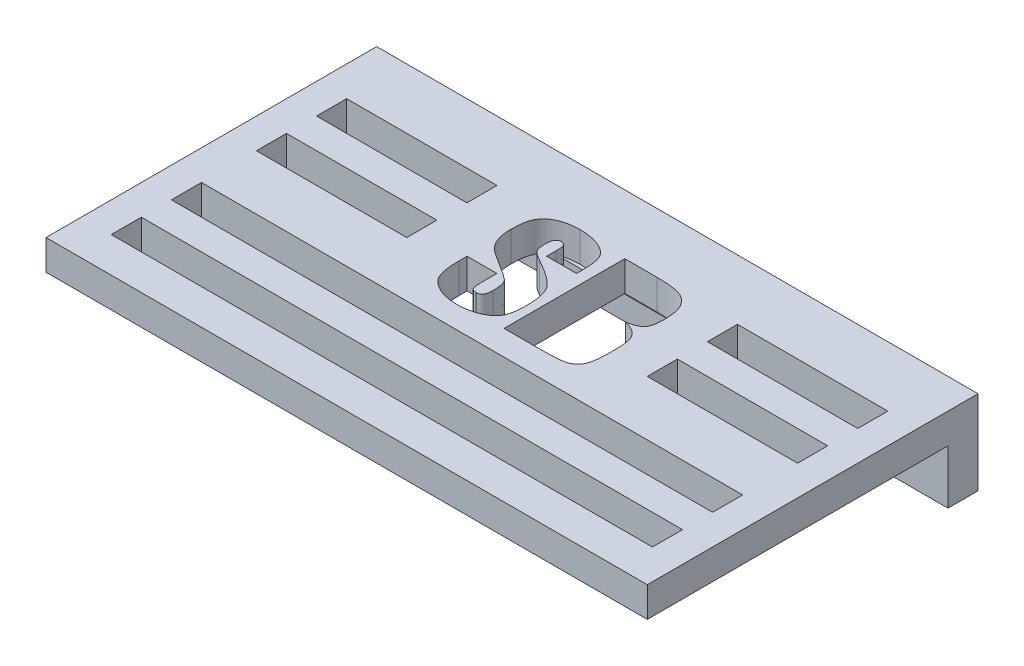
from build123d import *

# Parameters (mm, degrees)
SKETCH1_W           = 100
SKETCH1_H           = 50
BOSS_EXTRUDE1_DEPTH = 5
SKETCH2_W           = 100
SKETCH2_H           = 13.979624529
BOSS_EXTRUDE2_DEPTH = 5
SKETCH3_W           = 25
SKETCH3_H           = 5
SKETCH3_W_2         = 90
CUT_EXTRUDE1_DEPTH  = 5
CUT_EXTRUDE2_DEPTH  = 5
SKETCH5_W           = 5.529057523
SKETCH5_H           = 15.999161325
CUT_EXTRUDE3_DEPTH  = 5


with BuildPart() as part:
    # Sketch1 → Boss-Extrude1 (new body)
    with BuildSketch(Plane(origin=(0, 0, 0), x_dir=(1, 0, 0), z_dir=(0, 1, 0))):
        with Locations((1107.338709677, 577.567204301)):
            Rectangle(SKETCH1_W, SKETCH1_H)
    extrude(amount=BOSS_EXTRUDE1_DEPTH)

    # Sketch2 → Boss-Extrude2 (add)
    with BuildSketch(Plane(origin=(0, 0, -602.567204301), x_dir=(-1, 0, 0), z_dir=(0, 0, -1))):
        with Locations((-1107.338709677, -1.989812265)):
            Rectangle(SKETCH2_W, SKETCH2_H)
    extrude(amount=BOSS_EXTRUDE2_DEPTH)

    # Sketch3 → Cut-Extrude1 (cut)
    with BuildSketch(Plane(origin=(0, 5, 0), x_dir=(1, 0, 0), z_dir=(0, 1, 0))):
        with Locations((1074.838709677, 595.067204301)):
            Rectangle(SKETCH3_W, SKETCH3_H)
        with Locations((1139.838709677, 595.067204301)):
            Rectangle(SKETCH3_W, SKETCH3_H)
        with Locations((1139.838709677, 585.067204301)):
            Rectangle(SKETCH3_W, SKETCH3_H)
        with Locations((1074.838709677, 585.067204301)):
            Rectangle(SKETCH3_W, SKETCH3_H)
        with Locations((1107.338709677, 560.923142095)):
            Rectangle(SKETCH3_W_2, SKETCH3_H)
        with Locations((1107.338709677, 570.923142095)):
            Rectangle(SKETCH3_W_2, SKETCH3_H)
        with BuildLine():
            Line((1106.622574567, 591.504666387), (1101.661782977, 591.504666387))
            Line((1101.661782977, 591.504666387), (1101.661782977, 593.091824411))
            add(Edge.make_bspline(
                [(1101.661782977, 593.091824411), (1101.660519671, 593.260467079), (1101.658247272, 593.563816487), (1101.623631, 593.969134281), (1101.567949422, 594.276369068), (1101.480104346, 594.497949978), (1101.352985564, 594.64646604), (1101.19638039, 594.742361375), (1101.008066117, 594.804823716), (1100.871227987, 594.809409305), (1100.798073727, 594.811860781)],
                knots=[0, 0, 0, 0, 0.000505797, 0.000909813, 0.001218916, 0.001440411, 0.001615766, 0.001794963, 0.001985223, 0.002203776, 0.002203776, 0.002203776, 0.002203776], degree=3))
            add(Edge.make_bspline(
                [(1100.798073727, 594.811860781), (1100.718724347, 594.807066971), (1100.566086203, 594.797845497), (1100.350884239, 594.72171929), (1100.169040771, 594.59100808), (1100.017703118, 594.411626763), (1099.902676661, 594.180253753), (1099.831073964, 593.897343176), (1099.776182573, 593.567602693), (1099.773427651, 593.329571236), (1099.771957609, 593.202556366)],
                knots=[0, 0, 0, 0, 0.000237637, 0.000457123, 0.000674238, 0.00090204, 0.001154602, 0.001442079, 0.001774623, 0.002155089, 0.002155089, 0.002155089, 0.002155089], degree=3))
            add(Edge.make_bspline(
                [(1099.771957609, 593.202556366), (1099.773811748, 593.038706209), (1099.777278571, 592.732343195), (1099.827271783, 592.30569647), (1099.89577488, 591.939364377), (1099.982870155, 591.727609085), (1100.022950041, 591.630162603)],
                knots=[0, 0, 0, 0, 0.000491134, 0.00091831, 0.001288246, 0.00160361, 0.00160361, 0.00160361, 0.00160361], degree=3))
            add(Edge.make_bspline(
                [(1100.022950041, 591.630162603), (1100.047682192, 591.585158602), (1100.1007808, 591.488537414), (1100.211328399, 591.348238897), (1100.351801328, 591.199381722), (1100.529971675, 591.05226491), (1100.735457754, 590.893960242), (1100.974959613, 590.733105124), (1101.248679918, 590.568360619), (1101.442518799, 590.458411939), (1101.543668892, 590.401037901)],
                knots=[0, 0, 0, 0, 0.000153834, 0.000330273, 0.000533918, 0.000766923, 0.001022355, 0.001312074, 0.001631751, 0.00198061, 0.00198061, 0.00198061, 0.00198061], degree=3))
            add(Edge.make_bspline(
                [(1101.543668892, 590.401037901), (1101.836084256, 590.237603929), (1102.396319738, 589.924482524), (1103.187570699, 589.452326344), (1103.892671397, 589.000526415), (1104.510900685, 588.566920629), (1105.048370108, 588.161578328), (1105.495975834, 587.771080348), (1105.870343557, 587.411878993), (1106.064225792, 587.156483361), (1106.15380929, 587.03847753)],
                knots=[0, 0, 0, 0, 0.001004926, 0.001925327, 0.002763857, 0.00351649, 0.004190512, 0.004781843, 0.005298618, 0.005742483, 0.005742483, 0.005742483, 0.005742483], degree=3))
            add(Edge.make_bspline(
                [(1106.15380929, 587.03847753), (1106.23056521, 586.919563128), (1106.38980434, 586.672861293), (1106.578438953, 586.256034755), (1106.736540033, 585.789261002), (1106.868068819, 585.27338085), (1106.970934318, 584.704787569), (1107.042536959, 584.085902866), (1107.087412887, 583.415745425), (1107.092430943, 582.952544013), (1107.095030909, 582.71254915)],
                knots=[0, 0, 0, 0, 0.000424135, 0.000879918, 0.001367838, 0.001901398, 0.00247551, 0.003099987, 0.003769537, 0.004489446, 0.004489446, 0.004489446, 0.004489446], degree=3))
            add(Edge.make_bspline(
                [(1107.095030909, 582.71254915), (1107.094049095, 582.537801365), (1107.092146513, 582.199171078), (1107.065253586, 581.70919557), (1107.025294711, 581.254856746), (1106.972060591, 580.836717463), (1106.897355591, 580.455009818), (1106.810214387, 580.108204793), (1106.707627412, 579.795087805), (1106.585083717, 579.513886534), (1106.437609289, 579.256568825), (1106.261612904, 579.015479931), (1106.058626025, 578.782444266), (1105.824452352, 578.560867655), (1105.560842619, 578.348957816), (1105.265305647, 578.15189465), (1104.941077761, 577.962299109), (1104.467514652, 577.719664952), (1103.821187849, 577.468217492), (1102.989604562, 577.248680005), (1102.097662469, 577.119781031), (1101.48257242, 577.103233059), (1101.167180244, 577.094747959)],
                knots=[0, 0, 0, 0, 0.000524183, 0.001015774, 0.001471587, 0.001892336, 0.002279617, 0.002637707, 0.002964528, 0.00326697, 0.003556313, 0.003852382, 0.004161066, 0.004482189, 0.004818258, 0.005174517, 0.005546748, 0.005944579, 0.006769827, 0.007621256, 0.008520135, 0.009466085, 0.009466085, 0.009466085, 0.009466085], degree=3))
            add(Edge.make_bspline(
                [(1101.167180244, 577.094747959), (1100.991135927, 577.096054821), (1100.64592821, 577.098617464), (1100.138673202, 577.142950043), (1099.651500804, 577.202870526), (1099.183338193, 577.292909798), (1098.733947278, 577.405324903), (1098.304815825, 577.547947285), (1097.892879354, 577.707292832), (1097.507708948, 577.900882197), (1097.146351682, 578.110202289), (1096.814787726, 578.333454417), (1096.516410571, 578.572101049), (1096.249481104, 578.82254317), (1096.014967246, 579.089052864), (1095.816537918, 579.371615066), (1095.642672889, 579.662859038), (1095.509711959, 579.977281803), (1095.400104408, 580.312728007), (1095.301923899, 580.676903762), (1095.228770546, 581.075019818), (1095.160204381, 581.505419496), (1095.110309975, 581.968663008), (1095.073589936, 582.464757693), (1095.051329246, 582.992866384), (1095.048731946, 583.356003033), (1095.04739419, 583.543038813)],
                knots=[0, 0, 0, 0, 0.000527938, 0.001035242, 0.001526486, 0.001999922, 0.002464542, 0.002915094, 0.003355817, 0.003788302, 0.004206762, 0.004608071, 0.004986221, 0.005351767, 0.005704896, 0.006049017, 0.006386442, 0.006720376, 0.007070541, 0.00744478, 0.007850881, 0.008284168, 0.008752104, 0.009248083, 0.009776369, 0.01033746, 0.01033746, 0.01033746, 0.01033746], degree=3))
            Line((1095.04739419, 583.543038813), (1095.04739419, 584.890277601))
            Line((1095.04739419, 584.890277601), (1100.00818578, 584.890277601))
            Line((1100.00818578, 584.890277601), (1100.00818578, 582.288076655))
            add(Edge.make_bspline(
                [(1100.00818578, 582.288076655), (1100.008637117, 582.192082505), (1100.009493837, 582.009867766), (1100.022726451, 581.750377429), (1100.03352159, 581.517108637), (1100.062506571, 581.310904607), (1100.087368923, 581.129543819), (1100.130397308, 580.977596882), (1100.172366116, 580.850122199), (1100.240257665, 580.716831383), (1100.356740276, 580.585429685), (1100.53899432, 580.474387188), (1100.76478348, 580.413190095), (1100.928115092, 580.405872763), (1101.015846572, 580.401942353)],
                knots=[0, 0, 0, 0, 0.000287927, 0.000546538, 0.000779544, 0.000987852, 0.001171109, 0.001327794, 0.001460878, 0.001573137, 0.001774529, 0.001978374, 0.002205007, 0.002468007, 0.002468007, 0.002468007, 0.002468007], degree=3))
            add(Edge.make_bspline(
                [(1101.015846572, 580.401942353), (1101.105247193, 580.405835871), (1101.275951231, 580.413270265), (1101.511159944, 580.499115925), (1101.713111322, 580.631068973), (1101.869440061, 580.825130822), (1101.993095617, 581.067214064), (1102.072477668, 581.361268648), (1102.125191448, 581.702998563), (1102.131084141, 581.947024772), (1102.134239319, 582.07768594)],
                knots=[0, 0, 0, 0, 0.00026701, 0.000509836, 0.000741198, 0.000982222, 0.001248005, 0.001551705, 0.001891544, 0.002283232, 0.002283232, 0.002283232, 0.002283232], degree=3))
            add(Edge.make_bspline(
                [(1102.134239319, 582.07768594), (1102.132984609, 582.222905918), (1102.130579914, 582.501224933), (1102.108119819, 582.898934617), (1102.073925451, 583.259306316), (1102.017389329, 583.577920831), (1101.954278097, 583.859859434), (1101.8680436, 584.098343883), (1101.775867339, 584.304850138), (1101.690908008, 584.416614998), (1101.650709782, 584.469496171)],
                knots=[0, 0, 0, 0, 0.000435608, 0.000834858, 0.001194789, 0.00152065, 0.001805341, 0.002059837, 0.002281054, 0.002479722, 0.002479722, 0.002479722, 0.002479722], degree=3))
            add(Edge.make_bspline(
                [(1101.650709782, 584.469496171), (1101.602300283, 584.520771899), (1101.493388133, 584.636132518), (1101.292537344, 584.806486871), (1101.042598105, 584.997655855), (1100.749204711, 585.215844054), (1100.403333029, 585.451624393), (1100.009883249, 585.709354485), (1099.564056577, 585.986116788), (1099.250422975, 586.177454707), (1099.085419488, 586.278118105)],
                knots=[0, 0, 0, 0, 0.000211424, 0.000475664, 0.000788709, 0.001155613, 0.001572311, 0.002044263, 0.002566584, 0.003146446, 0.003146446, 0.003146446, 0.003146446], degree=3))
            add(Edge.make_bspline(
                [(1099.085419488, 586.278118105), (1098.920346854, 586.378673703), (1098.60279486, 586.572113585), (1098.150936623, 586.854661729), (1097.74237591, 587.117933583), (1097.38002398, 587.360048881), (1097.058994176, 587.578745066), (1096.783574223, 587.777240974), (1096.549210967, 587.953561185), (1096.295112723, 588.165867733), (1096.020499726, 588.448827748), (1095.727901374, 588.831350885), (1095.466546177, 589.270657833), (1095.231393364, 589.765318041), (1095.036332423, 590.325510129), (1094.910718024, 590.960146096), (1094.821637445, 591.662094758), (1094.814758011, 592.15520067), (1094.811166019, 592.41266842)],
                knots=[0, 0, 0, 0, 0.000579862, 0.001115486, 0.001598734, 0.002037908, 0.00242286, 0.002763979, 0.00305632, 0.003302545, 0.003756711, 0.004235839, 0.004744148, 0.00528735, 0.005876823, 0.006518219, 0.007224641, 0.007996507, 0.007996507, 0.007996507, 0.007996507], degree=3))
            add(Edge.make_bspline(
                [(1094.811166019, 592.41266842), (1094.813882699, 592.600928364), (1094.819123317, 592.964091774), (1094.842429626, 593.488953534), (1094.891279076, 593.974095394), (1094.955961137, 594.420403845), (1095.041123857, 594.828347634), (1095.141474187, 595.19872243), (1095.267926483, 595.527498964), (1095.409624184, 595.822389016), (1095.575063677, 596.089042794), (1095.764838188, 596.334574056), (1095.971719393, 596.571947084), (1096.209175435, 596.786331941), (1096.466102761, 596.991954434), (1096.745221032, 597.183610443), (1097.050028252, 597.35646293), (1097.490559719, 597.572188672), (1098.094362364, 597.79394742), (1098.880175591, 597.98581086), (1099.73536491, 598.100344835), (1100.328948599, 598.112680866), (1100.635666859, 598.119055174)],
                knots=[0, 0, 0, 0, 0.000564842, 0.001089609, 0.001575514, 0.002027047, 0.002441845, 0.002825147, 0.003176807, 0.003497059, 0.003805368, 0.004116164, 0.004427288, 0.00474858, 0.005074274, 0.005414172, 0.005763032, 0.006124549, 0.006884881, 0.007686998, 0.008547278, 0.009467094, 0.009467094, 0.009467094, 0.009467094], degree=3))
            add(Edge.make_bspline(
                [(1100.635666859, 598.119055174), (1100.806702459, 598.116489597), (1101.142876423, 598.111446904), (1101.637314565, 598.084830146), (1102.110550556, 598.025100546), (1102.566502223, 597.959833501), (1103.001659688, 597.860772251), (1103.419212433, 597.748845365), (1103.816143031, 597.611432324), (1104.191194903, 597.452630654), (1104.54175857, 597.280390384), (1104.866947872, 597.101952762), (1105.153664587, 596.901975241), (1105.419803213, 596.704201442), (1105.64323331, 596.481137957), (1105.847342334, 596.258096124), (1106.012153281, 596.01714449), (1106.150817884, 595.761472522), (1106.260877798, 595.476415971), (1106.361458804, 595.156508134), (1106.439540018, 594.790182143), (1106.511189919, 594.381852425), (1106.560112724, 593.926783548), (1106.596715078, 593.428217322), (1106.618724672, 592.88532004), (1106.621258465, 592.508656285), (1106.622574567, 592.31300966)],
                knots=[0, 0, 0, 0, 0.000513178, 0.001008661, 0.00148435, 0.001943736, 0.002389729, 0.00282223, 0.00324012, 0.003648696, 0.004043226, 0.004411778, 0.004759856, 0.005091353, 0.005404594, 0.005705297, 0.005997101, 0.006277841, 0.006575996, 0.006912227, 0.007282954, 0.007698621, 0.008155554, 0.008655213, 0.009198251, 0.009785177, 0.009785177, 0.009785177, 0.009785177], degree=3))
            Line((1106.622574567, 592.31300966), (1106.622574567, 591.504666387))
        make_face()
        with BuildLine():
            Line((1108.512399935, 597.646598832), (1113.838606977, 597.646598832))
            add(Edge.make_bspline(
                [(1113.838606977, 597.646598832), (1114.042851135, 597.644585937), (1114.437854849, 597.640693041), (1115.011437917, 597.627741715), (1115.547024533, 597.599219161), (1116.043865141, 597.55291118), (1116.503700196, 597.504399163), (1116.924602135, 597.437078935), (1117.307872242, 597.360815888), (1117.657583265, 597.272605536), (1117.979536692, 597.163827426), (1118.283450436, 597.036016088), (1118.569738952, 596.8793132), (1118.83907191, 596.697421237), (1119.09578723, 596.493845885), (1119.335131088, 596.265001294), (1119.558066535, 596.01145837), (1119.76684219, 595.733032269), (1119.958520089, 595.420319025), (1120.119971404, 595.062825832), (1120.254494672, 594.661499307), (1120.370409493, 594.218085676), (1120.451350175, 593.729733826), (1120.513809364, 593.198904113), (1120.556278399, 592.623739199), (1120.558754292, 592.224503997), (1120.560036654, 592.017724446)],
                knots=[0, 0, 0, 0, 0.000612761, 0.001185067, 0.001721085, 0.002221344, 0.002681944, 0.003107938, 0.003499556, 0.003854072, 0.004189065, 0.00451815, 0.004841892, 0.005166412, 0.005492106, 0.005823665, 0.006158394, 0.006503879, 0.0068666, 0.007256388, 0.007677768, 0.008135236, 0.008629798, 0.009161337, 0.009738573, 0.01035877, 0.01035877, 0.01035877, 0.01035877], degree=3))
            add(Edge.make_bspline(
                [(1120.560036654, 592.017724446), (1120.559451134, 591.878625239), (1120.558325222, 591.611147428), (1120.526736559, 591.226921049), (1120.483197411, 590.875828603), (1120.426753562, 590.555215885), (1120.345431969, 590.269191558), (1120.249664401, 590.013827008), (1120.13628025, 589.79084887), (1120.000097187, 589.596410518), (1119.83583775, 589.426277099), (1119.640228063, 589.27048181), (1119.413079841, 589.123729021), (1119.148735333, 588.99204888), (1118.855264676, 588.860225319), (1118.522070437, 588.750964836), (1118.158880442, 588.64042869), (1117.902908702, 588.582161467), (1117.769591384, 588.551814251)],
                knots=[0, 0, 0, 0, 0.000417156, 0.000802161, 0.001155598, 0.001478477, 0.001777612, 0.002046326, 0.002295603, 0.002526021, 0.002755758, 0.00300248, 0.00327482, 0.003565361, 0.003887669, 0.004239019, 0.004616249, 0.005026273, 0.005026273, 0.005026273, 0.005026273], degree=3))
            add(Edge.make_bspline(
                [(1117.769591384, 588.551814251), (1117.9116335, 588.516887162), (1118.185954629, 588.449433657), (1118.575608005, 588.319165415), (1118.929528297, 588.17215697), (1119.249780755, 588.010905036), (1119.532896703, 587.82874173), (1119.780632208, 587.629841237), (1119.995000404, 587.414910374), (1120.170505362, 587.17679379), (1120.320523305, 586.916437435), (1120.450176212, 586.627408092), (1120.554878496, 586.304953862), (1120.644078436, 585.951136086), (1120.713184128, 585.566377917), (1120.75998764, 585.148359194), (1120.789593102, 584.699997985), (1120.793995706, 584.389571758), (1120.796264824, 584.229576935)],
                knots=[0, 0, 0, 0, 0.000438678, 0.000847204, 0.001231075, 0.00158764, 0.001921411, 0.002239036, 0.002539195, 0.002829313, 0.003123698, 0.003439257, 0.00377775, 0.004139418, 0.004533273, 0.004949448, 0.005400725, 0.005880691, 0.005880691, 0.005880691, 0.005880691], degree=3))
            Line((1120.796264824, 584.229576935), (1120.796264824, 582.343442633))
            add(Edge.make_bspline(
                [(1120.796264824, 582.343442633), (1120.794947846, 582.17731836), (1120.79240043, 581.855986104), (1120.770097543, 581.390599001), (1120.733968112, 580.958336701), (1120.682912143, 580.559171938), (1120.617209669, 580.193045179), (1120.536687714, 579.859965603), (1120.441601991, 579.559664298), (1120.296804183, 579.210504894), (1120.073910613, 578.825262893), (1119.725528517, 578.439972491), (1119.308838513, 578.131672443), (1118.899142287, 577.943946993), (1118.515748779, 577.835328786), (1118.156684065, 577.762427031), (1117.731555519, 577.701066801), (1117.237323886, 577.656023188), (1116.678728028, 577.615107062), (1116.051077035, 577.585210305), (1115.356910153, 577.57320318), (1114.870876215, 577.569260375), (1114.617421728, 577.567204301)],
                knots=[0, 0, 0, 0, 0.000498348, 0.00096395, 0.001397379, 0.001799349, 0.002170755, 0.002512732, 0.002826733, 0.003114636, 0.003645752, 0.00415276, 0.00466214, 0.00519062, 0.005494321, 0.005856272, 0.006289009, 0.00678226, 0.007344769, 0.007969258, 0.008667025, 0.00942742, 0.00942742, 0.00942742, 0.00942742], degree=3))
            Line((1114.617421728, 577.567204301), (1108.512399935, 577.567204301))
            Line((1108.512399935, 577.567204301), (1108.512399935, 597.646598832))
        make_face()
        with BuildLine():
            Line((1113.709419696, 594.339404439), (1113.709419696, 589.851069191))
            add(Edge.make_bspline(
                [(1113.709419696, 589.851069191), (1113.818916889, 589.853765573), (1114.010832927, 589.85849153), (1114.202789577, 589.861045554), (1114.285225863, 589.862142386)],
                knots=[0, 0, 0, 0, 0.000328588, 0.000575917, 0.000575917, 0.000575917, 0.000575917], degree=3))
            add(Edge.make_bspline(
                [(1114.285225863, 589.862142386), (1114.414943004, 589.864472176), (1114.649961547, 589.868693236), (1114.964979994, 589.942683323), (1115.21072282, 590.056761907), (1115.358587497, 590.209778685), (1115.42977026, 590.371582109), (1115.476359742, 590.534091686), (1115.510380978, 590.741183572), (1115.544110567, 590.990890141), (1115.568601095, 591.286566844), (1115.586473645, 591.625052306), (1115.597467108, 592.007810964), (1115.598629487, 592.277321881), (1115.599245063, 592.42005055)],
                knots=[0, 0, 0, 0, 0.000388194, 0.000703321, 0.000964136, 0.001191339, 0.001321786, 0.001491133, 0.00169747, 0.001950651, 0.002247064, 0.002587143, 0.002967484, 0.003395664, 0.003395664, 0.003395664, 0.003395664], degree=3))
            add(Edge.make_bspline(
                [(1115.599245063, 592.42005055), (1115.597949944, 592.566586473), (1115.595561408, 592.836836686), (1115.558751957, 593.205786563), (1115.505439052, 593.506230619), (1115.418897706, 593.740070498), (1115.312642967, 593.919787925), (1115.192679653, 594.059860435), (1115.05862767, 594.167423529), (1114.896976484, 594.237745664), (1114.694234207, 594.280256298), (1114.431211706, 594.311109168), (1114.094815074, 594.332016955), (1113.846021752, 594.336785971), (1113.709419696, 594.339404439)],
                knots=[0, 0, 0, 0, 0.000439376, 0.000810324, 0.001111457, 0.001352085, 0.001554017, 0.001734577, 0.001902916, 0.002064819, 0.002258204, 0.002522366, 0.002858983, 0.00326884, 0.00326884, 0.00326884, 0.00326884], degree=3))
        make_face(mode=Mode.SUBTRACT)
        with BuildLine():
            Line((1113.709419696, 586.780102968), (1113.709419696, 580.874398694))
            add(Edge.make_bspline(
                [(1113.709419696, 580.874398694), (1113.806643083, 580.878745122), (1113.99144371, 580.88700674), (1114.255288116, 580.907730879), (1114.490352331, 580.941514123), (1114.699417133, 580.980252398), (1114.880549796, 581.032371415), (1115.035669497, 581.089985735), (1115.164519915, 581.155042801), (1115.266861061, 581.236435688), (1115.347490463, 581.33958612), (1115.418393672, 581.465644777), (1115.471179198, 581.625319117), (1115.518718853, 581.811404412), (1115.555192034, 582.027484799), (1115.578973913, 582.272925123), (1115.59953209, 582.547350445), (1115.599343475, 582.740801656), (1115.599245063, 582.841736431)],
                knots=[0, 0, 0, 0, 0.000291968, 0.000554967, 0.00079352, 0.001004169, 0.001192269, 0.001358162, 0.00150016, 0.001623521, 0.001746882, 0.001890644, 0.002055259, 0.002249523, 0.002466763, 0.00271174, 0.002989184, 0.003291874, 0.003291874, 0.003291874, 0.003291874], degree=3))
            Line((1115.599245063, 582.841736431), (1115.599245063, 584.812765232))
            add(Edge.make_bspline(
                [(1115.599245063, 584.812765232), (1115.598797161, 584.919808286), (1115.59794719, 585.122940738), (1115.584736202, 585.411366321), (1115.555514902, 585.6667401), (1115.532665848, 585.890320248), (1115.484926902, 586.07806589), (1115.436784466, 586.234656434), (1115.374154728, 586.357969778), (1115.301222422, 586.455359356), (1115.201806932, 586.525125575), (1115.08073656, 586.587455951), (1114.925799511, 586.63747267), (1114.741774038, 586.680679005), (1114.527180361, 586.716877526), (1114.282057041, 586.745966571), (1114.006226631, 586.76772702), (1113.811574914, 586.775843406), (1113.709419696, 586.780102968)],
                knots=[0, 0, 0, 0, 0.000321144, 0.000609425, 0.000865416, 0.001092499, 0.001282293, 0.001445703, 0.001582721, 0.001695706, 0.001806438, 0.001943456, 0.002103369, 0.002293163, 0.002510403, 0.002755797, 0.003033511, 0.003340225, 0.003340225, 0.003340225, 0.003340225], degree=3))
        make_face(mode=Mode.SUBTRACT)
    extrude(amount=-CUT_EXTRUDE1_DEPTH, mode=Mode.SUBTRACT)

    # Sketch4 → Cut-Extrude2 (cut)
    with BuildSketch(Plane(origin=(0, 0, -607.567204301), x_dir=(-1, 0, 0), z_dir=(0, 0, -1))):
        with BuildLine():
            Line((-1063.338709677, -5.029624529), (-1151.338709677, -5.029624529))
            ThreePointArc((-1151.338709677, -5.029624529), (-1153.388709677, -2.979624529), (-1151.338709677, -0.929624529))
            Line((-1151.338709677, -0.929624529), (-1063.338709677, -0.929624529))
            ThreePointArc((-1063.338709677, -0.929624529), (-1061.288709677, -2.979624529), (-1063.338709677, -5.029624529))
        make_face()
    extrude(amount=-CUT_EXTRUDE2_DEPTH, mode=Mode.SUBTRACT)

    # Sketch5 → Cut-Extrude3 (cut)
    with BuildSketch(Plane(origin=(0, 5, 0), x_dir=(1, 0, 0), z_dir=(0, 1, 0))):
        with Locations((1114.054568304, 588.220816532)):
            Rectangle(SKETCH5_W, SKETCH5_H)
    extrude(amount=-CUT_EXTRUDE3_DEPTH, mode=Mode.SUBTRACT)


solid = part.part
